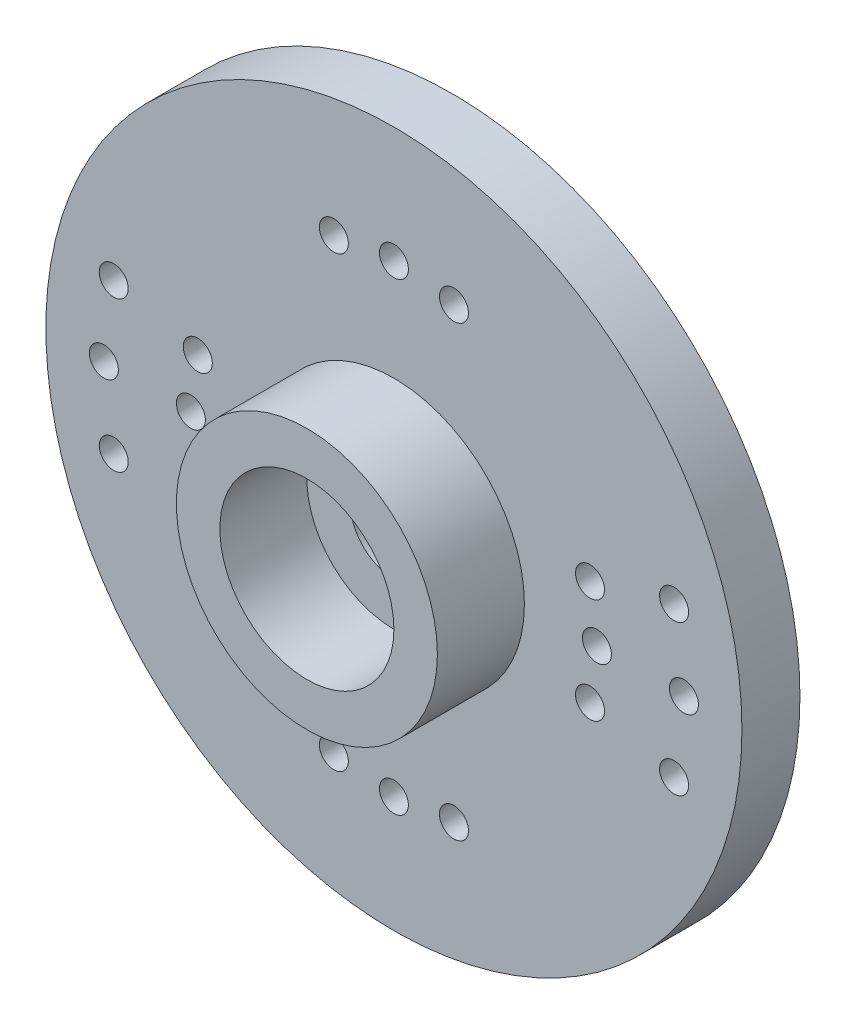
from build123d import *

# Parameters (mm, degrees)
SKETCH1_R           = 12
BOSS_EXTRUDE1_DEPTH = 2
SKETCH2_R           = 4.5
SKETCH2_R_2         = 3
BOSS_EXTRUDE2_DEPTH = 3
SKETCH3_R           = 1.5
CUT_EXTRUDE1_DEPTH  = 3
SKETCH4_R           = 4
SKETCH4_R_2         = 3
BOSS_EXTRUDE3_DEPTH = 1
SKETCH5_R           = 0.5
CUT_EXTRUDE2_DEPTH  = 2


with BuildPart() as part:
    # Sketch1 → Boss-Extrude1 (new body)
    with BuildSketch(Plane.XY):
        with Locations((-46.692941858, 3.175)):
            Circle(SKETCH1_R)
    extrude(amount=BOSS_EXTRUDE1_DEPTH)

    # Sketch2 → Boss-Extrude2 (add)
    with BuildSketch(Plane.XY.offset(2)):
        with Locations((-46.692941858, 3.175)):
            Circle(SKETCH2_R)
        with Locations((-46.692941858, 3.175)):
            Circle(SKETCH2_R_2, mode=Mode.SUBTRACT)
    extrude(amount=BOSS_EXTRUDE2_DEPTH)

    # Sketch3 → Cut-Extrude1 (cut)
    with BuildSketch(Plane.XY.offset(2)):
        with Locations((-46.692941858, 3.175)):
            Circle(SKETCH3_R)
    extrude(amount=-CUT_EXTRUDE1_DEPTH, mode=Mode.SUBTRACT)

    # Sketch4 → Boss-Extrude3 (add)
    with BuildSketch(Plane(origin=(0, 0, 0), x_dir=(-1, 0, 0), z_dir=(0, 0, -1))):
        with Locations((46.692941858, 3.175)):
            Circle(SKETCH4_R)
        with Locations((46.692941858, 3.175)):
            Circle(SKETCH4_R_2, mode=Mode.SUBTRACT)
    extrude(amount=BOSS_EXTRUDE3_DEPTH)

    # Sketch5 → Cut-Extrude2 (cut)
    with BuildSketch(Plane(origin=(0, 0, 0), x_dir=(-1, 0, 0), z_dir=(0, 0, -1))):
        with Locations((46.692941858, -4.825)):
            Circle(SKETCH5_R)
        with Locations((39.692941858, 3.175)):
            Circle(SKETCH5_R)
        with Locations((36.692941858, 3.175)):
            Circle(SKETCH5_R)
        with Locations((53.692941858, 3.175)):
            Circle(SKETCH5_R)
        with Locations((56.692941858, 3.175)):
            Circle(SKETCH5_R)
        with Locations((39.931461074, 1.363266684)):
            Circle(SKETCH5_R)
        with Locations((37.033683596, 0.586809549)):
            Circle(SKETCH5_R)
        with Locations((39.931461074, 4.986733316)):
            Circle(SKETCH5_R)
        with Locations((37.033683596, 5.763190451)):
            Circle(SKETCH5_R)
        with Locations((53.454422642, 4.986733316)):
            Circle(SKETCH5_R)
        with Locations((56.352200121, 5.763190451)):
            Circle(SKETCH5_R)
        with Locations((53.454422642, 1.363266684)):
            Circle(SKETCH5_R)
        with Locations((56.352200121, 0.586809549)):
            Circle(SKETCH5_R)
        with Locations((46.692941858, 11.175)):
            Circle(SKETCH5_R)
        with Locations((44.622389498, -4.55240661)):
            Circle(SKETCH5_R)
        with Locations((48.763494219, 10.90240661)):
            Circle(SKETCH5_R)
        with Locations((48.763494219, -4.55240661)):
            Circle(SKETCH5_R)
        with Locations((44.622389498, 10.90240661)):
            Circle(SKETCH5_R)
    extrude(amount=-CUT_EXTRUDE2_DEPTH, mode=Mode.SUBTRACT)


solid = part.part
